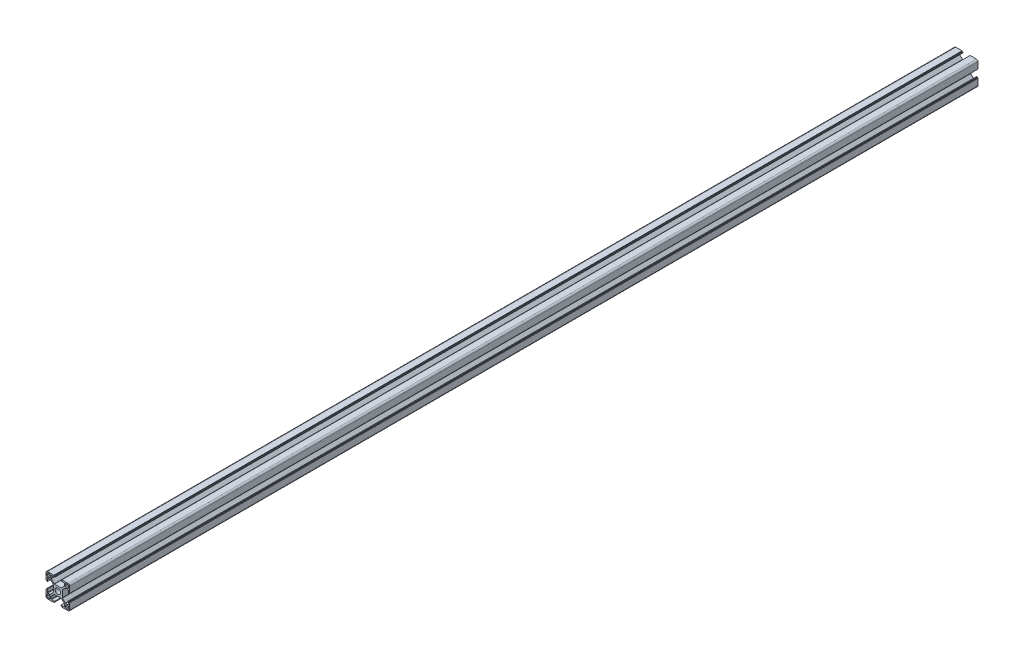
from build123d import *

# Parameters (mm, degrees)
SKETCH_1_W                       = 4
SKETCH_1_H                       = 4
EXTRUDE_1_DEPTH                  = 1150
FILLET_1_R                       = 1
FILLET_2_R                       = 2
FILLET_3_R                       = 0.5
PATTERN_CIRCULAR_1_COUNT         = 4
FILLET_1_OF_PATTERN_CIRCULAR_1_R = 1
FILLET_2_OF_PATTERN_CIRCULAR_1_R = 2
FILLET_3_OF_PATTERN_CIRCULAR_1_R = 0.5
SKETCH_2_R                       = 3.4
CUT_EXTRUDE_1_DEPTH              = 1151
SKETCH_3_R                       = 3.05
CUT_EXTRUDE_2_DEPTH              = 10
SKETCH_4_R                       = 2.6
SKETCH_4_R_2                     = 2.433498349
SKETCH_4_R_3                     = 2.371315545
CUT_EXTRUDE_3_DEPTH              = 100


with BuildPart() as part:
    # 草图1 → 凸台-拉伸1 (new body)
    with BuildSketch(Plane.XY):
        Polygon((5.7, 0), (5.7, 4.427207794), (9.672792206, 8.4), (13.2, 8.4), (13.2, 4.1), (14.1, 4.1), (14.1, 5.1), (15, 5.1), (15, 15), (5.1, 15), (5.1, 14.1), (4.1, 14.1), (4.1, 13.2), (8.4, 13.2), (8.4, 9.672792206), (4.427207794, 5.7), (0, 5.7), (0, 0), align=None)
        with Locations((11.7, 11.7)):
            Rectangle(SKETCH_1_W, SKETCH_1_H, mode=Mode.SUBTRACT)
    extrude_1 = extrude(amount=EXTRUDE_1_DEPTH)

    # 圆角1
    fillet_1_edges = [part.edges().sort_by_distance(p)[0] for p in [
        (13.7, 9.7, 575),
        (13.7, 13.7, 575),
        (9.7, 13.7, 575),
        (9.7, 9.7, 575),
    ]]
    fillet(fillet_1_edges, radius=FILLET_1_R)

    # 圆角2
    fillet_2_edges = [part.edges().sort_by_distance(p)[0] for p in [
        (15, 15, 575),
    ]]
    fillet(fillet_2_edges, radius=FILLET_2_R)

    # 圆角3
    fillet_3_edges = [part.edges().sort_by_distance(p)[0] for p in [
        (4.427207794, 5.7, 575),
        (8.4, 9.672792206, 575),
        (8.4, 13.2, 575),
        (13.2, 8.4, 575),
        (9.672792206, 8.4, 575),
        (5.7, 4.427207794, 575),
    ]]
    fillet(fillet_3_edges, radius=FILLET_3_R)

    # 阵列(圆周)1: 凸台-拉伸1 ×4 about axis
    pattern_circular_1_axis = Axis((0, 0, 0), (0, 0, 1))
    for i in range(1, PATTERN_CIRCULAR_1_COUNT):
        add(extrude_1.rotate(pattern_circular_1_axis, i * 360 / PATTERN_CIRCULAR_1_COUNT))

    # 圆角1 of 阵列(圆周)1
    fillet_1_of_pattern_circular_1_edges = [part.edges().sort_by_distance(p)[0] for p in [
        (-9.7, 13.7, 575),
        (-13.7, 13.7, 575),
        (-13.7, 9.7, 575),
        (-9.7, 9.7, 575),
        (-13.7, -9.7, 575),
        (-13.7, -13.7, 575),
        (-9.7, -13.7, 575),
        (-9.7, -9.7, 575),
        (9.7, -13.7, 575),
        (13.7, -13.7, 575),
        (13.7, -9.7, 575),
        (9.7, -9.7, 575),
    ]]
    fillet(fillet_1_of_pattern_circular_1_edges, radius=FILLET_1_OF_PATTERN_CIRCULAR_1_R)

    # 圆角2 of 阵列(圆周)1
    fillet_2_of_pattern_circular_1_edges = [part.edges().sort_by_distance(p)[0] for p in [
        (-15, 15, 575),
        (-15, -15, 575),
        (15, -15, 575),
    ]]
    fillet(fillet_2_of_pattern_circular_1_edges, radius=FILLET_2_OF_PATTERN_CIRCULAR_1_R)

    # 圆角3 of 阵列(圆周)1
    fillet_3_of_pattern_circular_1_edges = [part.edges().sort_by_distance(p)[0] for p in [
        (-5.7, 4.427207794, 575),
        (-9.672792206, 8.4, 575),
        (-13.2, 8.4, 575),
        (-8.4, 13.2, 575),
        (-8.4, 9.672792206, 575),
        (-4.427207794, 5.7, 575),
        (-4.427207794, -5.7, 575),
        (-8.4, -9.672792206, 575),
        (-8.4, -13.2, 575),
        (-13.2, -8.4, 575),
        (-9.672792206, -8.4, 575),
        (-5.7, -4.427207794, 575),
        (5.7, -4.427207794, 575),
        (9.672792206, -8.4, 575),
        (13.2, -8.4, 575),
        (8.4, -13.2, 575),
        (8.4, -9.672792206, 575),
        (4.427207794, -5.7, 575),
    ]]
    fillet(fillet_3_of_pattern_circular_1_edges, radius=FILLET_3_OF_PATTERN_CIRCULAR_1_R)

    # 草图2 → 切除-拉伸1 (cut, through all)
    with BuildSketch(Plane.XY.offset(1150)):
        Circle(SKETCH_2_R)
    extrude(amount=-CUT_EXTRUDE_1_DEPTH, mode=Mode.SUBTRACT)

    # 草图3 → 切除-拉伸2 (cut, symmetric)
    with BuildSketch(Plane(origin=(0, 0, 0), x_dir=(1, 0, 0), z_dir=(0, 1, 0))):
        with Locations((0, -70)):
            Circle(SKETCH_3_R)
        with Locations((0, -220)):
            Circle(SKETCH_3_R)
        with Locations((0, -930)):
            Circle(SKETCH_3_R)
        with Locations((0, -1080)):
            Circle(SKETCH_3_R)
    extrude(amount=CUT_EXTRUDE_2_DEPTH, both=True, mode=Mode.SUBTRACT)

    # 草图4 → 切除-拉伸3 (cut, symmetric)
    with BuildSketch(Plane(origin=(0, 0, 0), x_dir=(0, 0, -1), z_dir=(1, 0, 0))):
        with Locations((-610, 0)):
            Circle(SKETCH_4_R)
        with Locations((-550, 0)):
            Circle(SKETCH_4_R)
        with Locations((-490, 0)):
            Circle(SKETCH_4_R_2)
        with Locations((-445, 0)):
            Circle(SKETCH_4_R_3)
    extrude(amount=CUT_EXTRUDE_3_DEPTH, both=True, mode=Mode.SUBTRACT)


solid = part.part
